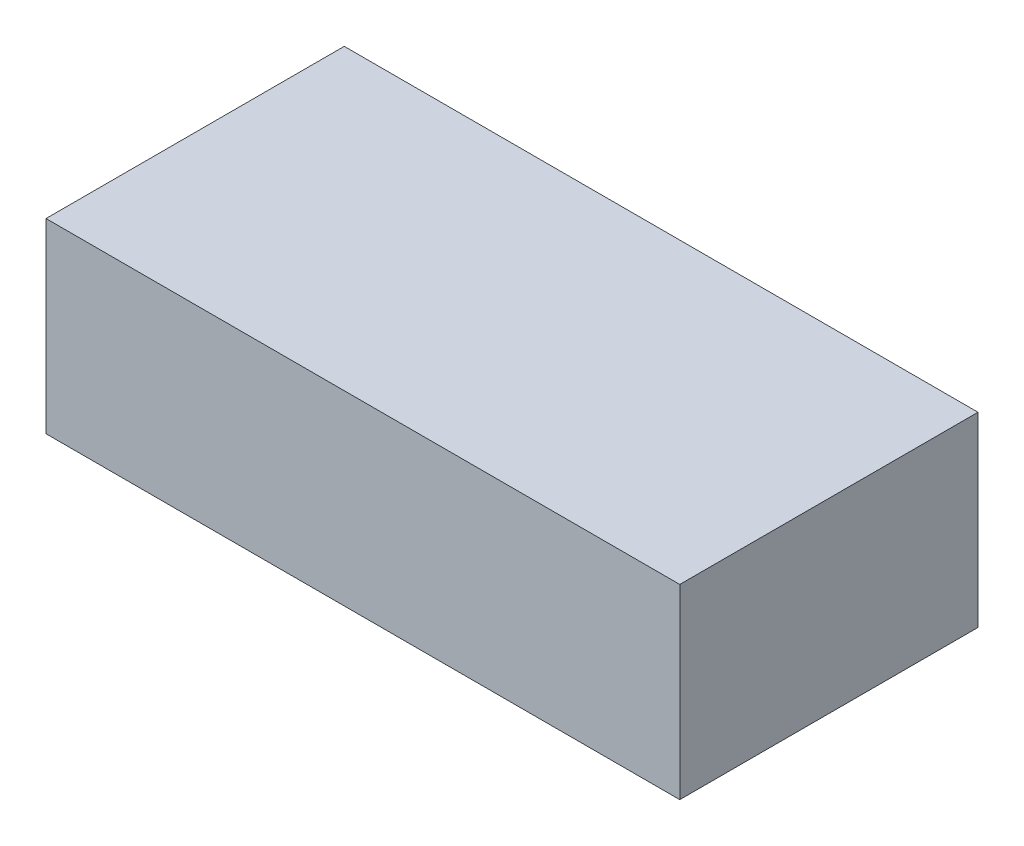
from build123d import *

# Parameters (mm, degrees)
SKETCH1_W     = 170
SKETCH1_H     = 50
BATTERY_DEPTH = 80


with BuildPart() as part:
    # Sketch1 → battery (new body)
    with BuildSketch(Plane.XY):
        with Locations((78.915295467, 104.862251837)):
            Rectangle(SKETCH1_W, SKETCH1_H)
    extrude(amount=BATTERY_DEPTH)


solid = part.part
